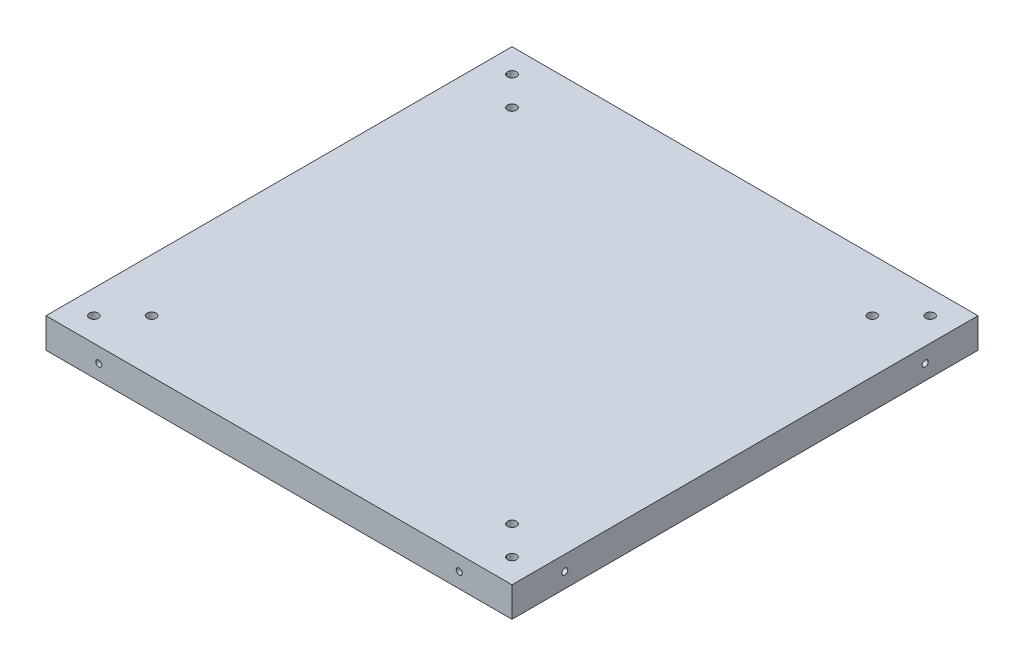
from build123d import *

# Parameters (mm, degrees)
SKETCH1_R           = 1.5
SKETCH1_R_2         = 73
BOSS_EXTRUDE1_DEPTH = 20
SKETCH4_R           = 73
SKETCH4_R_2         = 52.25
BOSS_EXTRUDE2_DEPTH = 10
SKETCH5_R           = 73
BOSS_EXTRUDE3_DEPTH = 10
CUT_EXTRUDE1_DEPTH  = 10
SKETCH7_W           = 155.702807198
SKETCH7_H           = 155.702807198
SKETCH7_R           = 1.5
BOSS_EXTRUDE4_DEPTH = 10
SKETCH8_R           = 1.5
CUT_EXTRUDE2_DEPTH  = 58
SKETCH9_R           = 3
CUT_EXTRUDE3_DEPTH  = 3
SKETCH10_R          = 3
CUT_EXTRUDE4_DEPTH  = 3
SKETCH11_R          = 3
SKETCH11_R_2        = 1.5
BOSS_EXTRUDE6_DEPTH = 3
SKETCH13_R          = 1
CUT_EXTRUDE6_DEPTH  = 5
SKETCH14_R          = 1
CUT_EXTRUDE7_DEPTH  = 5
SKETCH15_R          = 1
CUT_EXTRUDE8_DEPTH  = 5
SKETCH16_R          = 1
CUT_EXTRUDE9_DEPTH  = 5


with BuildPart() as part:
    # Sketch1 → Boss-Extrude1 (new body)
    with BuildSketch(Plane(origin=(0, 0, 0), x_dir=(1, 0, 0), z_dir=(0, 1, 0))):
        with BuildLine():
            Line((77.460838348, -75.098177713), (77.460838348, 74.577424045))
            ThreePointArc((77.460838348, 74.577424045), (76.578174547, 76.708362964), (74.447235628, 77.591026765))
            Line((74.447235628, 77.591026765), (-75.22836613, 77.591026765))
            ThreePointArc((-75.22836613, 77.591026765), (-77.359305049, 76.708362964), (-78.24196885, 74.577424045))
            Line((-78.24196885, 74.577424045), (-78.24196885, -75.098177713))
            ThreePointArc((-78.24196885, -75.098177713), (-77.359305049, -77.229116632), (-75.22836613, -78.111780433))
            Line((-75.22836613, -78.111780433), (74.447235628, -78.111780433))
            ThreePointArc((74.447235628, -78.111780433), (76.578174547, -77.229116632), (77.460838348, -75.098177713))
        make_face()
        with Locations((-60.604326536, -60.47413812)):
            Circle(SKETCH1_R, mode=Mode.SUBTRACT)
        with Locations((-60.604326536, 59.953384452)):
            Circle(SKETCH1_R, mode=Mode.SUBTRACT)
        with Locations((59.823196035, 59.953384452)):
            Circle(SKETCH1_R, mode=Mode.SUBTRACT)
        with Locations((59.823196035, -60.47413812)):
            Circle(SKETCH1_R, mode=Mode.SUBTRACT)
        Circle(SKETCH1_R_2, mode=Mode.SUBTRACT)
    extrude(amount=BOSS_EXTRUDE1_DEPTH)

    # Sketch4 → Boss-Extrude2 (add)
    with BuildSketch(Plane(origin=(0, 20, 0), x_dir=(1, 0, 0), z_dir=(0, 1, 0))):
        Circle(SKETCH4_R)
        Circle(SKETCH4_R_2, mode=Mode.SUBTRACT)
    extrude(amount=-BOSS_EXTRUDE2_DEPTH)

    # Sketch5 → Boss-Extrude3 (add)
    with BuildSketch(Plane.XZ.offset(-10)):
        Circle(SKETCH5_R)
    extrude(amount=BOSS_EXTRUDE3_DEPTH)

    # Sketch6 → Cut-Extrude1 (cut)
    with BuildSketch(Plane(origin=(0, 20, 0), x_dir=(1, 0, 0), z_dir=(0, 1, 0))):
        with BuildLine():
            Line((77.460838348, -75.098177713), (77.460838348, 74.577424045))
            ThreePointArc((77.460838348, 74.577424045), (76.578174547, 76.708362964), (74.447235628, 77.591026765))
            Line((74.447235628, 77.591026765), (-75.22836613, 77.591026765))
            ThreePointArc((-75.22836613, 77.591026765), (-77.359305049, 76.708362964), (-78.24196885, 74.577424045))
            Line((-78.24196885, 74.577424045), (-78.24196885, -75.098177713))
            ThreePointArc((-78.24196885, -75.098177713), (-77.359305049, -77.229116632), (-75.22836613, -78.111780433))
            Line((-75.22836613, -78.111780433), (74.447235628, -78.111780433))
            ThreePointArc((74.447235628, -78.111780433), (76.578174547, -77.229116632), (77.460838348, -75.098177713))
        make_face()
    extrude(amount=-CUT_EXTRUDE1_DEPTH, mode=Mode.SUBTRACT)

    # Sketch7 → Boss-Extrude4 (add)
    with BuildSketch(Plane(origin=(0, 10, 0), x_dir=(1, 0, 0), z_dir=(0, 1, 0))):
        with Locations((-0.390565251, -0.260376834)):
            Rectangle(SKETCH7_W, SKETCH7_H)
        with Locations((59.823196035, 59.953384452)):
            Circle(SKETCH7_R, mode=Mode.SUBTRACT)
        with Locations((59.823196035, -60.47413812)):
            Circle(SKETCH7_R, mode=Mode.SUBTRACT)
        with Locations((-60.604326536, -60.47413812)):
            Circle(SKETCH7_R, mode=Mode.SUBTRACT)
        with Locations((-60.604326536, 59.953384452)):
            Circle(SKETCH7_R, mode=Mode.SUBTRACT)
    extrude(amount=-BOSS_EXTRUDE4_DEPTH)

    # Sketch8 → Cut-Extrude2 (cut)
    with BuildSketch(Plane(origin=(0, 10, 0), x_dir=(1, 0, 0), z_dir=(0, 1, 0))):
        with Locations((-70.24196885, 69.591026765)):
            Circle(SKETCH8_R)
        with Locations((69.460838348, 69.591026765)):
            Circle(SKETCH8_R)
        with Locations((69.460838348, -70.111780433)):
            Circle(SKETCH8_R)
        with Locations((-70.24196885, -70.111780433)):
            Circle(SKETCH8_R)
    extrude(amount=-CUT_EXTRUDE2_DEPTH, mode=Mode.SUBTRACT)

    # Sketch9 → Cut-Extrude3 (cut)
    with BuildSketch(Plane(origin=(0, 10, 0), x_dir=(1, 0, 0), z_dir=(0, 1, 0))):
        with Locations((-60.604326536, 59.953384452)):
            Circle(SKETCH9_R)
        with Locations((59.823196035, 59.953384452)):
            Circle(SKETCH9_R)
        with Locations((59.823196035, -60.47413812)):
            Circle(SKETCH9_R)
        with Locations((-60.604326536, -60.47413812)):
            Circle(SKETCH9_R)
    extrude(amount=-CUT_EXTRUDE3_DEPTH, mode=Mode.SUBTRACT)

    # Sketch10 → Cut-Extrude4 (cut)
    with BuildSketch(Plane.XZ):
        with Locations((59.823196035, -59.953384452)):
            Circle(SKETCH10_R)
        with Locations((-60.604326536, -59.953384452)):
            Circle(SKETCH10_R)
        with Locations((-60.604326536, 60.47413812)):
            Circle(SKETCH10_R)
        with Locations((59.823196035, 60.47413812)):
            Circle(SKETCH10_R)
    extrude(amount=-CUT_EXTRUDE4_DEPTH, mode=Mode.SUBTRACT)

    # Sketch11 → Boss-Extrude6 (add)
    with BuildSketch(Plane(origin=(0, 10, 0), x_dir=(1, 0, 0), z_dir=(0, 1, 0))):
        with Locations((-60.604326536, -60.47413812)):
            Circle(SKETCH11_R)
        with Locations((-60.604326536, -60.47413812)):
            Circle(SKETCH11_R_2, mode=Mode.SUBTRACT)
        with Locations((59.823196035, -60.47413812)):
            Circle(SKETCH11_R)
        with Locations((59.823196035, -60.47413812)):
            Circle(SKETCH11_R_2, mode=Mode.SUBTRACT)
        with Locations((59.823196035, 59.953384452)):
            Circle(SKETCH11_R)
        with Locations((59.823196035, 59.953384452)):
            Circle(SKETCH11_R_2, mode=Mode.SUBTRACT)
        with Locations((-60.604326536, 59.953384452)):
            Circle(SKETCH11_R)
        with Locations((-60.604326536, 59.953384452)):
            Circle(SKETCH11_R_2, mode=Mode.SUBTRACT)
    extrude(amount=-BOSS_EXTRUDE6_DEPTH)

    # Sketch13 → Cut-Extrude6 (cut)
    with BuildSketch(Plane(origin=(0, 0, -77.591026765), x_dir=(-1, 0, 0), z_dir=(0, 0, -1))):
        with Locations((-59.823196035, 5)):
            Circle(SKETCH13_R)
        with Locations((60.604326536, 5)):
            Circle(SKETCH13_R)
    extrude(amount=-CUT_EXTRUDE6_DEPTH, mode=Mode.SUBTRACT)

    # Sketch14 → Cut-Extrude7 (cut)
    with BuildSketch(Plane.ZY.offset(78.24196885)):
        with Locations((-59.953384452, 5)):
            Circle(SKETCH14_R)
        with Locations((60.47413812, 5)):
            Circle(SKETCH14_R)
    extrude(amount=-CUT_EXTRUDE7_DEPTH, mode=Mode.SUBTRACT)

    # Sketch15 → Cut-Extrude8 (cut)
    with BuildSketch(Plane.XY.offset(78.111780433)):
        with Locations((-60.604326536, 5)):
            Circle(SKETCH15_R)
        with Locations((59.823196035, 5)):
            Circle(SKETCH15_R)
    extrude(amount=-CUT_EXTRUDE8_DEPTH, mode=Mode.SUBTRACT)

    # Sketch16 → Cut-Extrude9 (cut)
    with BuildSketch(Plane(origin=(77.460838348, 0, 0), x_dir=(0, 0, -1), z_dir=(1, 0, 0))):
        with Locations((59.953384452, 5)):
            Circle(SKETCH16_R)
        with Locations((-60.47413812, 5)):
            Circle(SKETCH16_R)
    extrude(amount=-CUT_EXTRUDE9_DEPTH, mode=Mode.SUBTRACT)


solid = part.part
